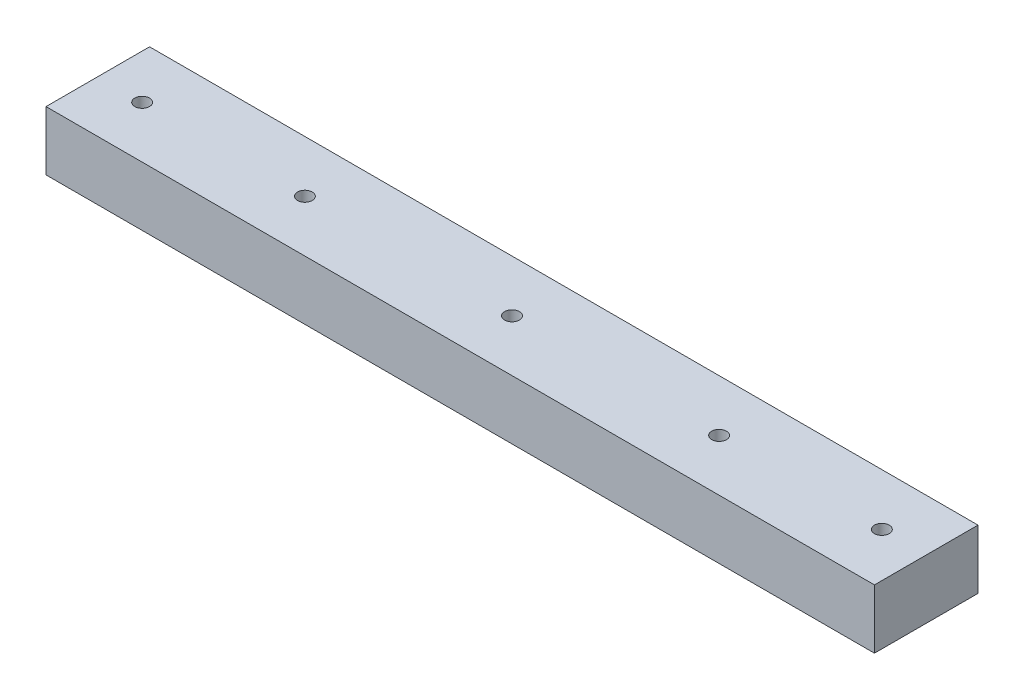
from build123d import *

# Parameters (mm, degrees)
SKETCH1_W             = 280
SKETCH1_H             = 35
EXTRUDE1_DEPTH        = 20
M6_TAPPED_HOLE1_D     = 5
M6_TAPPED_HOLE1_DEPTH = 29
M6_TAPPED_HOLE1_TIP   = 1.502151548


with BuildPart() as part:
    # Sketch1 → Extrude1 (new body)
    with BuildSketch(Plane(origin=(0, 0, 0), x_dir=(1, 0, 0), z_dir=(0, 1, 0))):
        Rectangle(SKETCH1_W, SKETCH1_H)
    extrude(amount=EXTRUDE1_DEPTH)

    # M6 Tapped Hole1
    with Locations(Plane(origin=(0, 0, 0), x_dir=(-1, 0, 0), z_dir=(0, -1, 0))):
        with Locations((-125, 0), (-70, 0), (0, 0), (70, 0), (125, 0)):
            Hole(M6_TAPPED_HOLE1_D / 2, depth=M6_TAPPED_HOLE1_DEPTH)
            with Locations((0, 0, -(M6_TAPPED_HOLE1_DEPTH + M6_TAPPED_HOLE1_TIP / 2))):  # 118° drill point
                Cone(0, M6_TAPPED_HOLE1_D / 2, M6_TAPPED_HOLE1_TIP, mode=Mode.SUBTRACT)


solid = part.part
